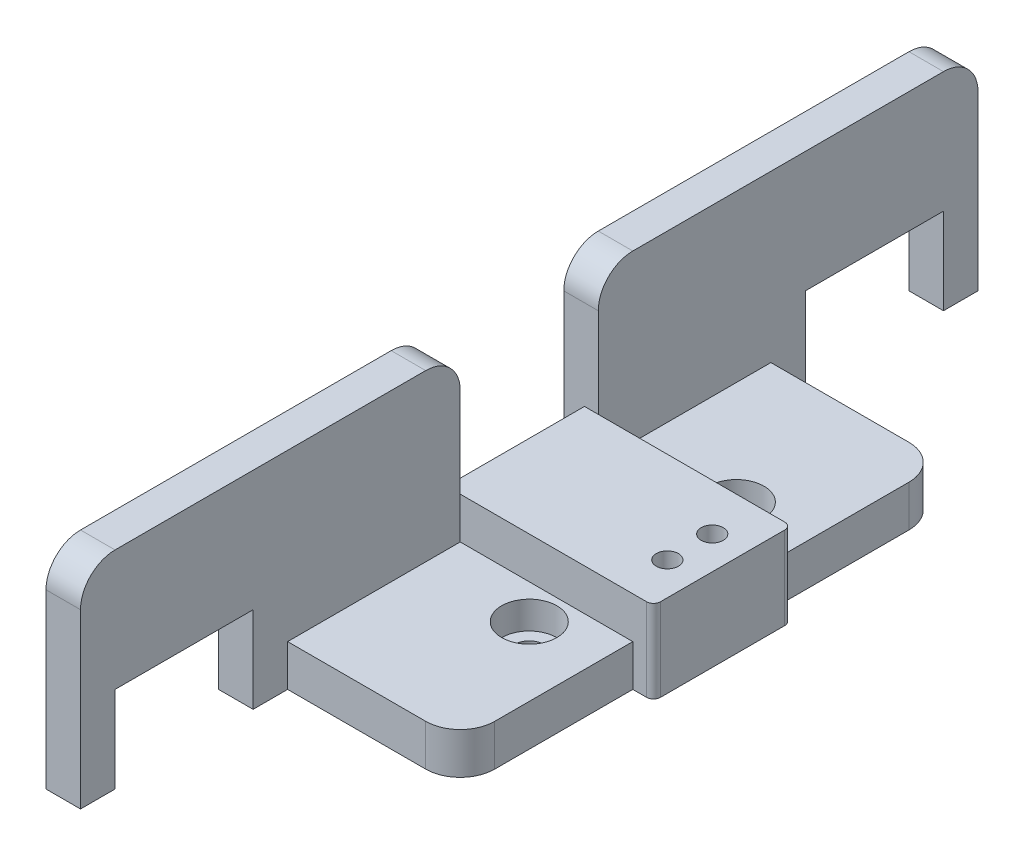
from build123d import *

# Parameters (mm, degrees)
BOSS_EXTRUDE1_DEPTH            = 6
SKETCH2_W                      = 5
SKETCH2_H                      = 130
BOSS_EXTRUDE2_DEPTH            = 24
SKETCH3_W                      = 20
SKETCH3_H                      = 12.5
CUT_EXTRUDE1_DEPTH             = 31
CBORE_FOR_M4_SHCS1_D           = 4.5
CBORE_FOR_M4_SHCS1_CBORE_D     = 8
CBORE_FOR_M4_SHCS1_CBORE_DEPTH = 4
SKETCH9_W                      = 5
SKETCH9_H                      = 20
CUT_EXTRUDE2_DEPTH             = 18
SKETCH10_W                     = 33
SKETCH10_H                     = 20
BOSS_EXTRUDE3_DEPTH            = 12
FILLET1_R                      = 5
SKETCH13_R                     = 2.5
CUT_EXTRUDE3_DEPTH             = 4.1
CHAMFER1_SIZE                  = 3
SKETCH11_R                     = 1.6
CUT_EXTRUDE4_DEPTH             = 4.5
FILLET3_R                      = 1


with BuildPart() as part:
    # Sketch1 → Boss-Extrude1 (new body)
    with BuildSketch(Plane(origin=(0, 0, 0), x_dir=(1, 0, 0), z_dir=(0, 1, 0))):
        Polygon((-25, -35), (-25, -65), (-30, -65), (-30, 65), (-25, 65), (-25, 35), (0, 35), (0, -35), align=None)
    extrude(amount=BOSS_EXTRUDE1_DEPTH)

    # Sketch2 → Boss-Extrude2 (add)
    with BuildSketch(Plane(origin=(0, 6, 0), x_dir=(1, 0, 0), z_dir=(0, 1, 0))):
        with Locations((-27.5, 0)):
            Rectangle(SKETCH2_W, SKETCH2_H)
    extrude(amount=BOSS_EXTRUDE2_DEPTH)

    # Sketch3 → Cut-Extrude1 (cut, through all)
    with BuildSketch(Plane.ZY.offset(30)):
        with Locations((-50, 6.25)):
            Rectangle(SKETCH3_W, SKETCH3_H)
        with Locations((50, 6.25)):
            Rectangle(SKETCH3_W, SKETCH3_H)
    extrude(amount=-CUT_EXTRUDE1_DEPTH, mode=Mode.SUBTRACT)

    # CBORE for M4 SHCS1 (through all)
    with Locations(Plane(origin=(0, 6, 0), x_dir=(1, 0, 0), z_dir=(0, 1, 0))):
        with Locations((-10, 15), (-10, -15)):
            CounterBoreHole(CBORE_FOR_M4_SHCS1_D / 2, CBORE_FOR_M4_SHCS1_CBORE_D / 2, CBORE_FOR_M4_SHCS1_CBORE_DEPTH)

    # Sketch9 → Cut-Extrude2 (cut)
    with BuildSketch(Plane(origin=(0, 30, 0), x_dir=(1, 0, 0), z_dir=(0, 1, 0))):
        with Locations((-27.5, 0)):
            Rectangle(SKETCH9_W, SKETCH9_H)
    extrude(amount=-CUT_EXTRUDE2_DEPTH, mode=Mode.SUBTRACT)

    # Sketch10 → Boss-Extrude3 (add, through all)
    with BuildSketch(Plane(origin=(0, 12, 0), x_dir=(1, 0, 0), z_dir=(0, 1, 0))):
        with Locations((-13.5, 0)):
            Rectangle(SKETCH10_W, SKETCH10_H)
    extrude(amount=-BOSS_EXTRUDE3_DEPTH)

    # Fillet1
    fillet1_edges = [part.edges().sort_by_distance(p)[0] for p in [
        (-27.5, 30, 10),
        (-27.5, 30, -10),
        (0, 3, -35),
        (0, 3, 35),
        (-27.5, 30, 65),
        (-27.5, 30, -65),
    ]]
    fillet(fillet1_edges, radius=FILLET1_R)

    # Sketch13 → Cut-Extrude3 (cut)
    with BuildSketch(Plane.ZY.offset(30)):
        with Locations((-20, 6)):
            Circle(SKETCH13_R)
        with Locations((20, 6)):
            Circle(SKETCH13_R)
    extrude(amount=-CUT_EXTRUDE3_DEPTH, mode=Mode.SUBTRACT)

    # Chamfer1
    chamfer1_edges = [part.edges().sort_by_distance(p)[0] for p in [
        (-30, 12, 0),
    ]]
    chamfer(chamfer1_edges, length=CHAMFER1_SIZE)

    # Sketch11 → Cut-Extrude4 (cut)
    with BuildSketch(Plane(origin=(0, 12, 0), x_dir=(1, 0, 0), z_dir=(0, 1, 0))):
        with Locations((-1.75, 3.25)):
            Circle(SKETCH11_R)
        with Locations((-1.75, -3.25)):
            Circle(SKETCH11_R)
    extrude(amount=-CUT_EXTRUDE4_DEPTH, mode=Mode.SUBTRACT)

    # Fillet3
    fillet3_edges = [part.edges().sort_by_distance(p)[0] for p in [
        (3, 6, 10),
        (3, 6, -10),
    ]]
    fillet(fillet3_edges, radius=FILLET3_R)


solid = part.part
